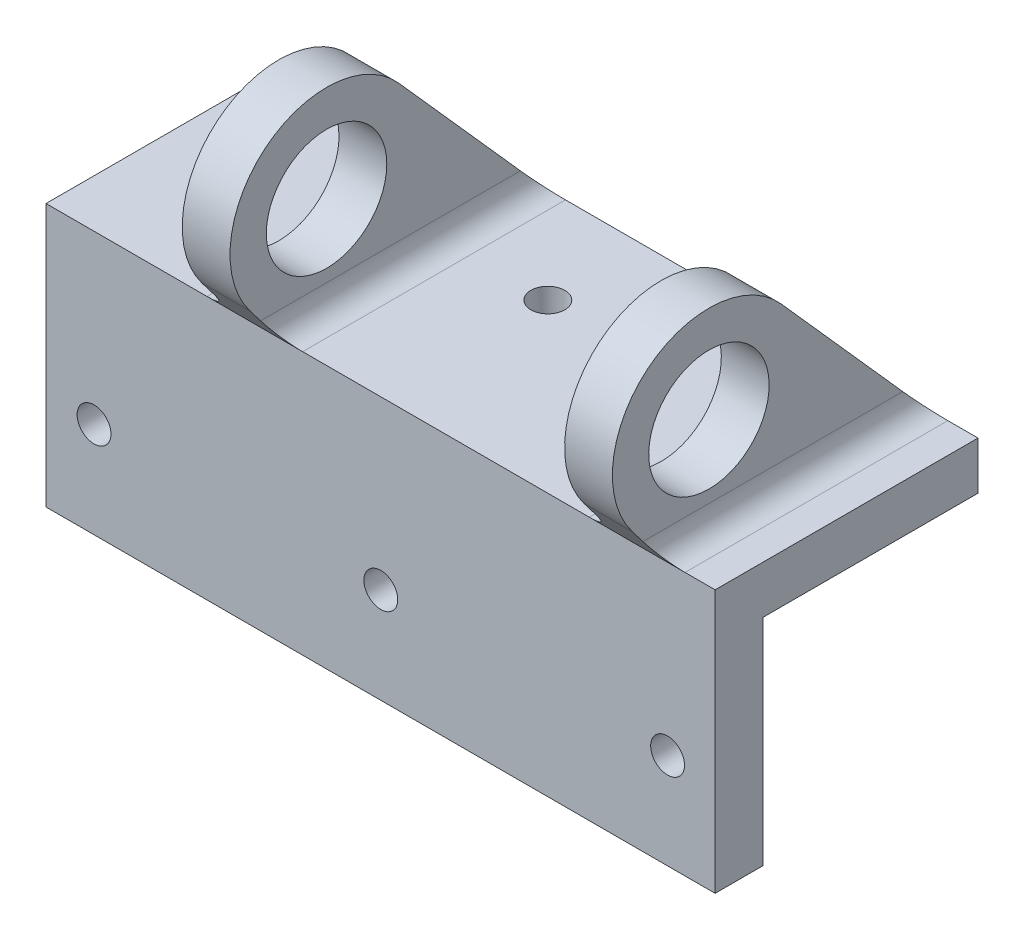
from build123d import *
from build123d.topology import SkipClean

# Parameters (mm, degrees)
SKETCH1_W           = 88.9
SKETCH1_H           = 28.575
SKETCH1_R           = 2.25
BOSS_EXTRUDE1_DEPTH = 6.35
SKETCH2_W           = 24.575
SKETCH2_H           = 28.575
SKETCH2_R           = 2.25
SKETCH2_W_2         = 6.35
SKETCH2_H_2         = 6.35
SKETCH2_W_3         = 7.175
BOSS_EXTRUDE2_DEPTH = 6.35
SKETCH2_4_W         = 6.35
SKETCH2_4_H         = 28.575
BOSS_EXTRUDE3_DEPTH = 38.1
BOSS_EXTRUDE4_DEPTH = 6.35
CUT_EXTRUDE1_DEPTH  = 97.028
BOSS_EXTRUDE5_START = -6.35
BOSS_EXTRUDE5_DEPTH = 6.35
FILLET1_R           = 3.175


with BuildPart() as part:
    # Sketch1 → Boss-Extrude1 (new body)
    with BuildSketch(Plane.XY):
        Rectangle(SKETCH1_W, SKETCH1_H)
        with Locations((-38.066912716, -1.5875)):
            Circle(SKETCH1_R, mode=Mode.SUBTRACT)
        with Locations((0.033087284, -1.5875)):
            Circle(SKETCH1_R, mode=Mode.SUBTRACT)
        with Locations((38.133087284, -1.5875)):
            Circle(SKETCH1_R, mode=Mode.SUBTRACT)
    extrude(amount=BOSS_EXTRUDE1_DEPTH)

    # Sketch2 → Boss-Extrude2 (add)
    # profile 1 of 10: a face of its own
    with BuildSketch(Plane(origin=(0, 14.2875, 0), x_dir=(1, 0, 0), z_dir=(0, 1, 0))):
        with Locations((-32.1625, 14.2875)):
            Rectangle(SKETCH2_W, SKETCH2_H)
        with Locations(Location((-38.1, 15.875, 0), (0, 0, 180))):
            Circle(SKETCH2_R, mode=Mode.SUBTRACT)
    # profile 2 of 10: a face of its own
    with BuildSketch(Plane(origin=(0, 14.2875, 0), x_dir=(1, 0, 0), z_dir=(0, 1, 0))):
        with Locations((-16.7, 14.2875)):
            Rectangle(SKETCH2_W_2, SKETCH2_H)
    # profile 3 of 10: a face of its own
    with BuildSketch(Plane(origin=(0, 14.2875, 0), x_dir=(1, 0, 0), z_dir=(0, 1, 0))):
        with Locations((-32.1625, -3.175)):
            Rectangle(SKETCH2_W, SKETCH2_H_2)
    # profile 4 of 10: a face of its own
    with BuildSketch(Plane(origin=(0, 14.2875, 0), x_dir=(1, 0, 0), z_dir=(0, 1, 0))):
        with Locations((-16.7, -3.175)):
            Rectangle(SKETCH2_W_2, SKETCH2_H_2)
    # profile 5 of 10: a face of its own
    with BuildSketch(Plane(origin=(0, 14.2875, 0), x_dir=(1, 0, 0), z_dir=(0, 1, 0))):
        Polygon((-13.525, 28.575), (-13.525, 0), (30.925, 0), (30.925, 28.575), (21.4, 28.575), (-4, 28.575), align=None)
        with Locations(Location((0, 15.875, 0), (0, 0, 180))):
            Circle(SKETCH2_R, mode=Mode.SUBTRACT)
    # profile 6 of 10: a face of its own
    with BuildSketch(Plane(origin=(0, 14.2875, 0), x_dir=(1, 0, 0), z_dir=(0, 1, 0))):
        Polygon((-13.525, 0), (-13.525, -6.35), (-4, -6.35), (21.4, -6.35), (30.925, -6.35), (30.925, 0), align=None)
    # profile 7 of 10: a face of its own
    with BuildSketch(Plane(origin=(0, 14.2875, 0), x_dir=(1, 0, 0), z_dir=(0, 1, 0))):
        with Locations((34.1, 14.2875)):
            Rectangle(SKETCH2_W_2, SKETCH2_H)
    # profile 8 of 10: a face of its own
    with BuildSketch(Plane(origin=(0, 14.2875, 0), x_dir=(1, 0, 0), z_dir=(0, 1, 0))):
        with Locations((40.8625, 14.2875)):
            Rectangle(SKETCH2_W_3, SKETCH2_H)
    # profile 9 of 10: a face of its own
    with BuildSketch(Plane(origin=(0, 14.2875, 0), x_dir=(1, 0, 0), z_dir=(0, 1, 0))):
        with Locations((40.8625, -3.175)):
            Rectangle(SKETCH2_W_3, SKETCH2_H_2)
    # profile 10 of 10: a face of its own
    with BuildSketch(Plane(origin=(0, 14.2875, 0), x_dir=(1, 0, 0), z_dir=(0, 1, 0))):
        with Locations((34.1, -3.175)):
            Rectangle(SKETCH2_W_2, SKETCH2_H_2)
    extrude(amount=BOSS_EXTRUDE2_DEPTH)

    # Sketch2_4 → Boss-Extrude3 (add)
    with BuildSketch(Plane(origin=(0, 14.2875, 0), x_dir=(1, 0, 0), z_dir=(0, 1, 0))):
        with Locations((-16.7, 14.2875)):
            Rectangle(SKETCH2_4_W, SKETCH2_4_H)
        with Locations((34.1, 14.2875)):
            Rectangle(SKETCH2_4_W, SKETCH2_4_H)
    extrude(amount=BOSS_EXTRUDE3_DEPTH)

    # Sketch3 → Boss-Extrude4 (add)
    with BuildSketch(Plane.ZY.offset(19.875)):
        with BuildLine():
            ThreePointArc((0, 20.6375), (5.69066224, 21.969154609), (10.199570624, 25.687579802))
            ThreePointArc((10.199570624, 25.687579802), (12.150928324, 29.359383395), (12.825, 33.4625))
            ThreePointArc((12.825, 33.4625), (9.068644469, 42.531144469), (0, 46.2875))
            Line((0, 46.2875), (0, 41.4625))
            ThreePointArc((0, 41.4625), (5.656854249, 39.119354249), (8, 33.4625))
            ThreePointArc((8, 33.4625), (5.656854249, 27.805645751), (0, 25.4625))
            Line((0, 25.4625), (0, 20.6375))
        make_face()
        with BuildLine():
            ThreePointArc((-9.582018268, 41.986909124), (-11.700559218, 28.21106791), (0, 20.6375))
            Line((0, 20.6375), (0, 25.4625))
            ThreePointArc((0, 25.4625), (-8, 33.4625), (0, 41.4625))
            Line((0, 41.4625), (0, 46.2875))
            ThreePointArc((0, 46.2875), (-5.25143209, 45.163059218), (-9.582018268, 41.986909124))
        make_face()
        with BuildLine():
            Line((0, 20.6375), (6.35, 20.6375))
            Line((6.35, 20.6375), (10.199570624, 25.687579802))
            ThreePointArc((10.199570624, 25.687579802), (5.69066224, 21.969154609), (0, 20.6375))
        make_face()
    extrude(amount=-BOSS_EXTRUDE4_DEPTH)

    # Sketch3_4 → Cut-Extrude1 (cut)
    with SkipClean():  # the faces are left unmerged after this step: merging them gives an invalid solid
        with BuildSketch(Plane.ZY.offset(19.875)):
            with BuildLine():
                Line((-28.575, 20.6375), (-9.582018268, 41.986909124))
                ThreePointArc((-9.582018268, 41.986909124), (-5.25143209, 45.163059218), (0, 46.2875))
                Line((0, 46.2875), (0, 52.3875))
                Line((0, 52.3875), (-28.575, 52.3875))
                Line((-28.575, 52.3875), (-28.575, 20.6375))
            make_face()
            with BuildLine():
                Line((0, 41.4625), (0, 25.4625))
                ThreePointArc((0, 25.4625), (5.656854249, 27.805645751), (8, 33.4625))
                ThreePointArc((8, 33.4625), (5.656854249, 39.119354249), (0, 41.4625))
            make_face()
            with BuildLine():
                ThreePointArc((0, 41.4625), (-8, 33.4625), (0, 25.4625))
                Line((0, 25.4625), (0, 41.4625))
            make_face()
        extrude(amount=-CUT_EXTRUDE1_DEPTH, mode=Mode.SUBTRACT)

    # Sketch4 → Boss-Extrude5 (add)
    with SkipClean():  # the faces are left unmerged after this step: merging them gives an invalid solid
        with BuildSketch(Plane(origin=(37.275, 0, 0), x_dir=(0, 0, -1), z_dir=(1, 0, 0)).offset(BOSS_EXTRUDE5_START)):
            with BuildLine():
                Line((0, 46.2875), (0, 41.4625))
                ThreePointArc((0, 41.4625), (8, 33.4625), (0, 25.4625))
                Line((0, 25.4625), (0, 20.6375))
                Line((0, 20.6375), (28.575, 20.6375))
                Line((28.575, 20.6375), (9.582018268, 41.986909124))
                ThreePointArc((9.582018268, 41.986909124), (5.25143209, 45.163059218), (0, 46.2875))
            make_face()
            with BuildLine():
                Line((-6.35, 20.6375), (0, 20.6375))
                Line((0, 20.6375), (0, 25.4625))
                ThreePointArc((0, 25.4625), (-8, 33.4625), (0, 41.4625))
                Line((0, 41.4625), (0, 46.2875))
                ThreePointArc((0, 46.2875), (-11.493345391, 39.15316224), (-10.199570624, 25.687579802))
                Line((-10.199570624, 25.687579802), (-6.35, 20.6375))
            make_face()
        extrude(amount=BOSS_EXTRUDE5_DEPTH)

    # Fillet1
    fillet1_edges = [part.edges().sort_by_distance(p)[0] for p in [
        (-13.525, 20.6375, -11.1125),
        (-19.875, 20.6375, -11.1125),
        (30.925, 20.6375, -14.2875),
        (37.275, 20.6375, -14.2875),
    ]]
    fillet(fillet1_edges, radius=FILLET1_R)


solid = part.part
